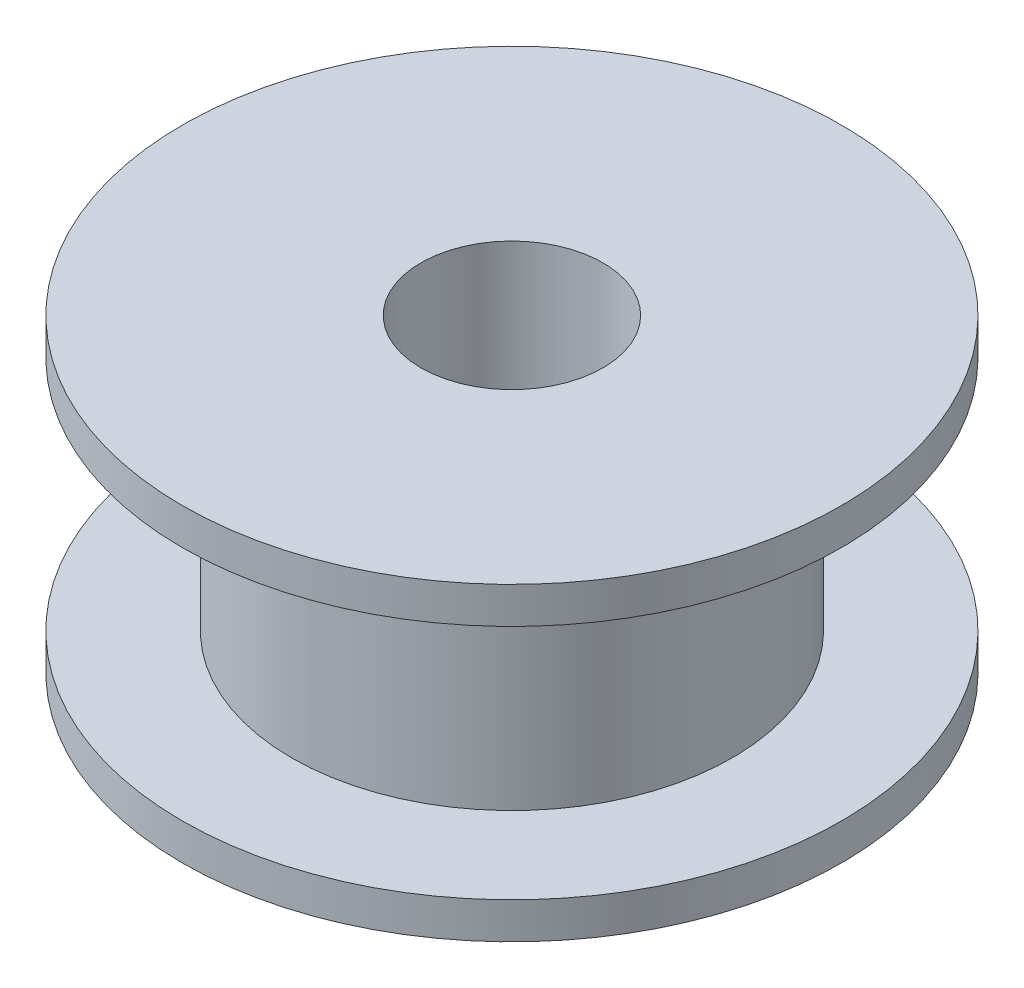
from build123d import *

# Parameters (mm, degrees)
SKETCH1_R           = 9.05
SKETCH1_R_2         = 6.05
SKETCH1_R_3         = 2.5
BOSS_EXTRUDE1_DEPTH = 1
BOSS_EXTRUDE2_START = 1
SKETCH1_3_R         = 6.05
SKETCH1_3_R_2       = 2.5
BOSS_EXTRUDE2_DEPTH = 3.25


with BuildPart() as part:
    # Sketch1 → Boss-Extrude1 (new body)
    with BuildSketch(Plane(origin=(0, 0, 0), x_dir=(1, 0, 0), z_dir=(0, 1, 0))):
        Circle(SKETCH1_R)
        Circle(SKETCH1_R_2, mode=Mode.SUBTRACT)
        Circle(SKETCH1_R_2)
        Circle(SKETCH1_R_3, mode=Mode.SUBTRACT)
    extrude(amount=BOSS_EXTRUDE1_DEPTH)

    # Sketch1_3 → Boss-Extrude2 (add)
    with BuildSketch(Plane(origin=(0, 0, 0), x_dir=(1, 0, 0), z_dir=(0, 1, 0)).offset(BOSS_EXTRUDE2_START)):
        Circle(SKETCH1_3_R)
        Circle(SKETCH1_3_R_2, mode=Mode.SUBTRACT)
    extrude(amount=BOSS_EXTRUDE2_DEPTH)

    # Mirror2: part across plane


with BuildPart() as part_1:
    add(part.part)
    add(part.part.mirror(Plane.ZX.offset(4.25)))


solid = part_1.part
